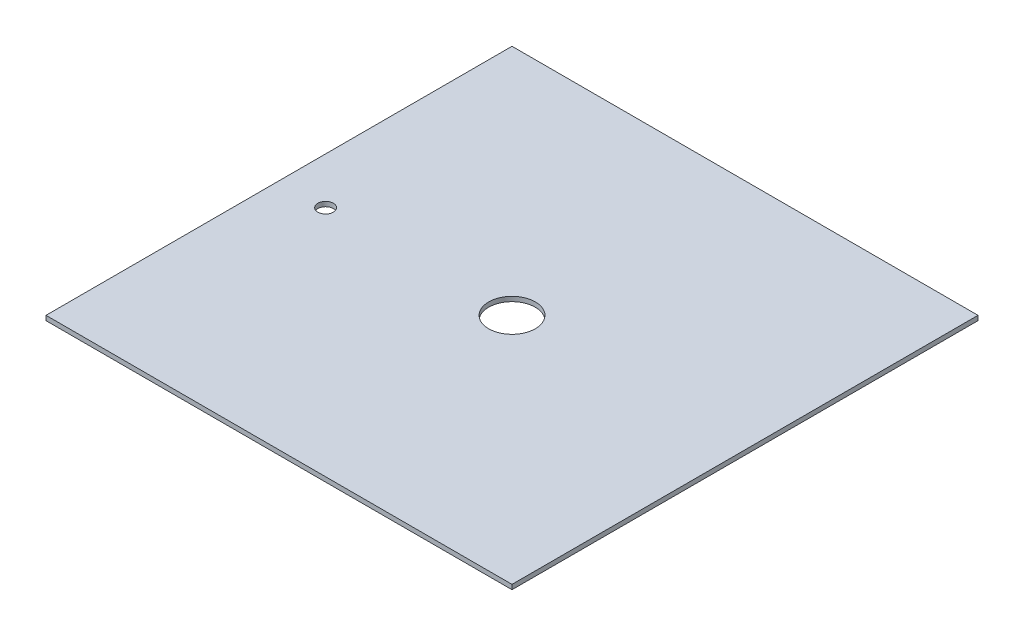
from build123d import *

# Parameters (mm, degrees)
SKETCH2_W           = 300
SKETCH2_H           = 300
BOSS_EXTRUDE1_DEPTH = 3
SKETCH3_R           = 15
CUT_EXTRUDE1_DEPTH  = 4
SKETCH4_R           = 5
CUT_EXTRUDE2_DEPTH  = 4


with BuildPart() as part:
    # Sketch2 → Boss-Extrude1 (new body)
    with BuildSketch(Plane(origin=(0, 0, 0), x_dir=(1, 0, 0), z_dir=(0, 1, 0))):
        Rectangle(SKETCH2_W, SKETCH2_H)
    extrude(amount=BOSS_EXTRUDE1_DEPTH)

    # Sketch3 → Cut-Extrude1 (cut, through all)
    with BuildSketch(Plane(origin=(0, 3, 0), x_dir=(1, 0, 0), z_dir=(0, 1, 0))):
        Circle(SKETCH3_R)
    extrude(amount=-CUT_EXTRUDE1_DEPTH, mode=Mode.SUBTRACT)

    # Sketch4 → Cut-Extrude2 (cut, through all)
    with BuildSketch(Plane(origin=(0, 3, 0), x_dir=(1, 0, 0), z_dir=(0, 1, 0))):
        with Locations((-120, 0)):
            Circle(SKETCH4_R)
    extrude(amount=-CUT_EXTRUDE2_DEPTH, mode=Mode.SUBTRACT)


solid = part.part
